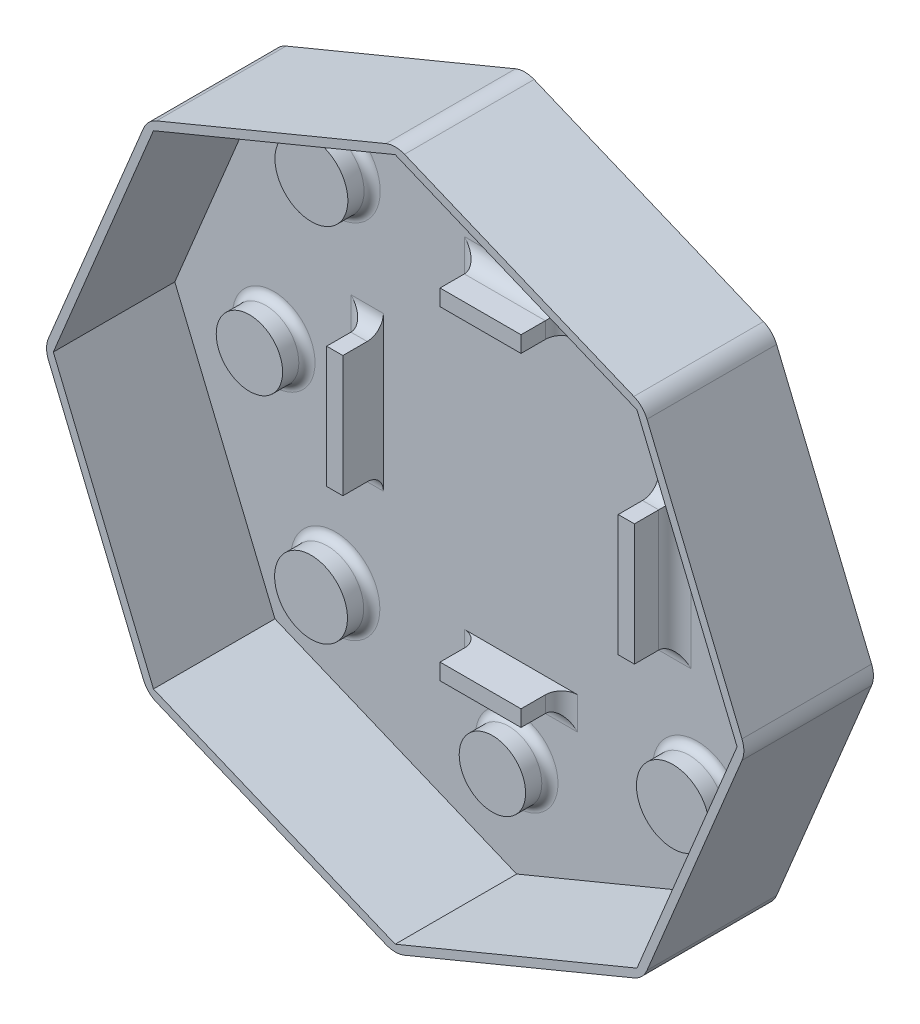
from build123d import *

# Parameters (mm, degrees)
BOSS_EXTRU_1_DEPTH      = 10
ESQUISSE2_R             = 3.1
ENL_V_MAT_EXTRU_1_DEPTH = 3
COQUE2_T                = -1
ESQUISSE5_R             = 4.5
BOSS_EXTRU_3_DEPTH      = 3
CONG_1_R                = 3
CONG_4_R                = 1
ESQUISSE6_W             = 2
ESQUISSE6_H             = 15
ESQUISSE6_W_2           = 10
ESQUISSE6_H_2           = 2
BOSS_EXTRU_4_DEPTH      = 5
CONG_5_R                = 2
BOSS_EXTRU_5_DEPTH      = 6


with BuildPart() as part:
    # Esquisse1 → Boss.-Extru.1 (new body)
    with BuildSketch(Plane.XY):
        Polygon((0, -43.295688012), (30.614674589, -30.614674589), (43.295688012, 0), (30.614674589, 30.614674589), (0, 43.295688012), (-30.614674589, 30.614674589), (-43.295688012, 0), (-30.614674589, -30.614674589), align=None)
    extrude(amount=BOSS_EXTRU_1_DEPTH)

    # Esquisse2 → Enlèv. mat.-Extru.1 (cut)
    with BuildSketch(Plane(origin=(0, 0, 0), x_dir=(-1, 0, 0), z_dir=(0, 0, -1))):
        with Locations((0, 30)):
            Circle(ESQUISSE2_R)
        with Locations((30, 0)):
            Circle(ESQUISSE2_R)
        with Locations((0, -30)):
            Circle(ESQUISSE2_R)
        with Locations((-30, 0)):
            Circle(ESQUISSE2_R)
    extrude(amount=-ENL_V_MAT_EXTRU_1_DEPTH, mode=Mode.SUBTRACT)

    # Coque2
    coque2_openings = [part.faces().sort_by_distance(p)[0] for p in [
        (0, 0, 10),
    ]]
    offset(amount=COQUE2_T, openings=coque2_openings, kind=Kind.INTERSECTION)

    # Esquisse5 → Boss.-Extru.3 (add)
    with BuildSketch(Plane.XY.offset(1)):
        with Locations((-22.348932936, 22.369089211)):
            Circle(ESQUISSE5_R)
        with Locations((-22.393864563, -22.310165371)):
            Circle(ESQUISSE5_R)
        with Locations((22.285390019, -22.355096998)):
            Circle(ESQUISSE5_R)
        with Locations((22.330321646, 22.324157584)):
            Circle(ESQUISSE5_R)
    extrude(amount=BOSS_EXTRU_3_DEPTH)

    # Congé1
    cong_1_edges = [part.edges().sort_by_distance(p)[0] for p in [
        (30.614674589, -30.614674589, 5),
        (0, -43.295688012, 5),
        (-30.614674589, -30.614674589, 5),
        (-43.295688012, 0, 5),
        (-30.614674589, 30.614674589, 5),
        (0, 43.295688012, 5),
        (30.614674589, 30.614674589, 5),
        (43.295688012, 0, 5),
    ]]
    fillet(cong_1_edges, radius=CONG_1_R)

    # Congé4
    cong_4_edges = [part.edges().sort_by_distance(p)[0] for p in [
        (34.1, 0, 1),
        (4.1, -30, 1),
        (-25.9, 0, 1),
        (4.1, 30, 1),
        (-26.848932936, 22.369089211, 1),
        (-26.893864563, -22.310165371, 1),
        (17.785390019, -22.355096998, 1),
        (17.830321646, 22.324157584, 1),
    ]]
    fillet(cong_4_edges, radius=CONG_4_R)

    # Esquisse6 → Boss.-Extru.4 (add)
    with BuildSketch(Plane.XY.offset(1)):
        with Locations((-17.464495368, 0)):
            Rectangle(ESQUISSE6_W, ESQUISSE6_H)
        with Locations((18.535504632, 0)):
            Rectangle(ESQUISSE6_W, ESQUISSE6_H)
        with Locations((0.535504632, 19.72199452)):
            Rectangle(ESQUISSE6_W_2, ESQUISSE6_H_2)
        with Locations((0.535504632, -20.27800548)):
            Rectangle(ESQUISSE6_W_2, ESQUISSE6_H_2)
    extrude(amount=BOSS_EXTRU_4_DEPTH)

    # Congé5
    cong_5_edges = [part.edges().sort_by_distance(p)[0] for p in [
        (-18.464495368, 0, 1),
        (-17.464495368, -7.5, 1),
        (-17.464495368, 7.5, 1),
        (18.535504632, -7.5, 1),
        (19.535504632, 0, 1),
        (18.535504632, 7.5, 1),
        (0.535504632, 20.72199452, 1),
        (-4.464495368, 19.72199452, 1),
        (5.535504632, 19.72199452, 1),
        (-4.464495368, -20.27800548, 1),
        (0.535504632, -21.27800548, 1),
        (5.535504632, -20.27800548, 1),
    ]]
    fillet(cong_5_edges, radius=CONG_5_R)

    # Esquisse7 → Boss.-Extru.5 (add)
    with BuildSketch(Plane.XY.offset(10)):
        with BuildLine():
            Line((-1.148050297, 42.820150008), (-29.466624292, 31.090212593))
            ThreePointArc((-29.466624292, 31.090212593), (-30.439894339, 30.439894339), (-31.090212593, 29.466624292))
            Line((-31.090212593, 29.466624292), (-42.820150008, 1.148050297))
            ThreePointArc((-42.820150008, 1.148050297), (-43.048511411, 0), (-42.820150008, -1.148050297))
            Line((-42.820150008, -1.148050297), (-31.090212593, -29.466624292))
            ThreePointArc((-31.090212593, -29.466624292), (-30.439894339, -30.439894339), (-29.466624292, -31.090212593))
            Line((-29.466624292, -31.090212593), (-1.148050297, -42.820150008))
            ThreePointArc((-1.148050297, -42.820150008), (0, -43.048511411), (1.148050297, -42.820150008))
            Line((1.148050297, -42.820150008), (29.466624292, -31.090212593))
            ThreePointArc((29.466624292, -31.090212593), (30.439894339, -30.439894339), (31.090212593, -29.466624292))
            Line((31.090212593, -29.466624292), (42.820150008, -1.148050297))
            ThreePointArc((42.820150008, -1.148050297), (43.048511411, 0), (42.820150008, 1.148050297))
            Line((42.820150008, 1.148050297), (31.090212593, 29.466624292))
            ThreePointArc((31.090212593, 29.466624292), (30.439894339, 30.439894339), (29.466624292, 31.090212593))
            Line((29.466624292, 31.090212593), (1.148050297, 42.820150008))
            ThreePointArc((1.148050297, 42.820150008), (0, 43.048511411), (-1.148050297, 42.820150008))
        make_face()
        Polygon((-42.213295811, 0), (-29.849307724, -29.849307724), (0, -42.213295811), (29.849307724, -29.849307724), (42.213295811, 0), (29.849307724, 29.849307724), (0, 42.213295811), (-29.849307724, 29.849307724), align=None, mode=Mode.SUBTRACT)
    extrude(amount=BOSS_EXTRU_5_DEPTH)


solid = part.part
